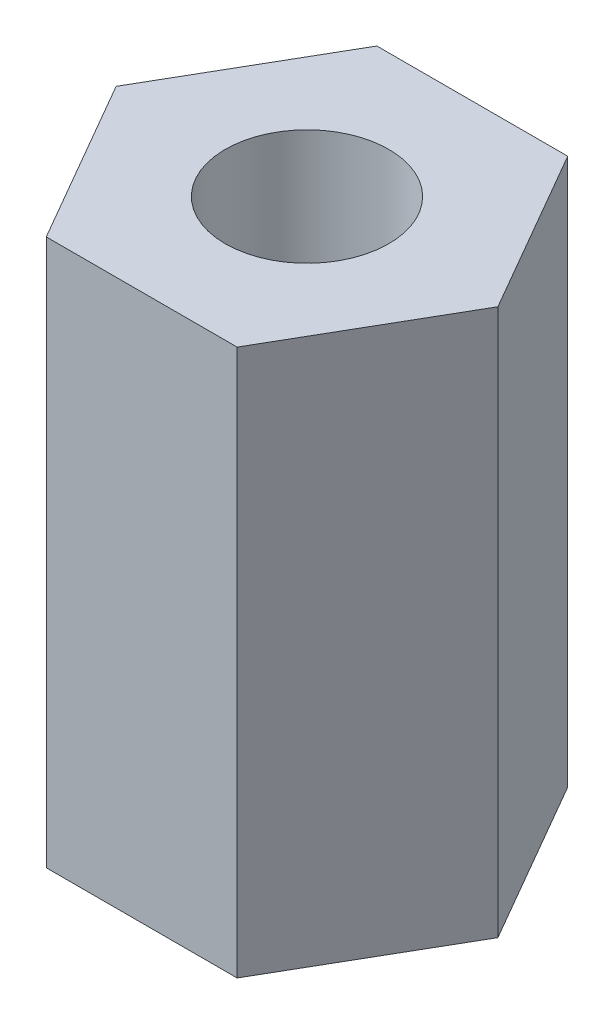
from build123d import *

# Parameters (mm, degrees)
SKETCH1_R           = 2.9845
BOSS_EXTRUDE1_DEPTH = 9.9695


with BuildPart() as part:
    # Sketch1 → Boss-Extrude1 (new body, symmetric)
    with BuildSketch(Plane(origin=(0, 0, 0), x_dir=(1, 0, 0), z_dir=(0, 1, 0))):
        Polygon((6.965730998, 0), (3.482865499, 6.0325), (-3.482865499, 6.0325), (-6.965730998, 0), (-3.482865499, -6.0325), (3.482865499, -6.0325), align=None)
        Circle(SKETCH1_R, mode=Mode.SUBTRACT)
    extrude(amount=BOSS_EXTRUDE1_DEPTH, both=True)


solid = part.part
